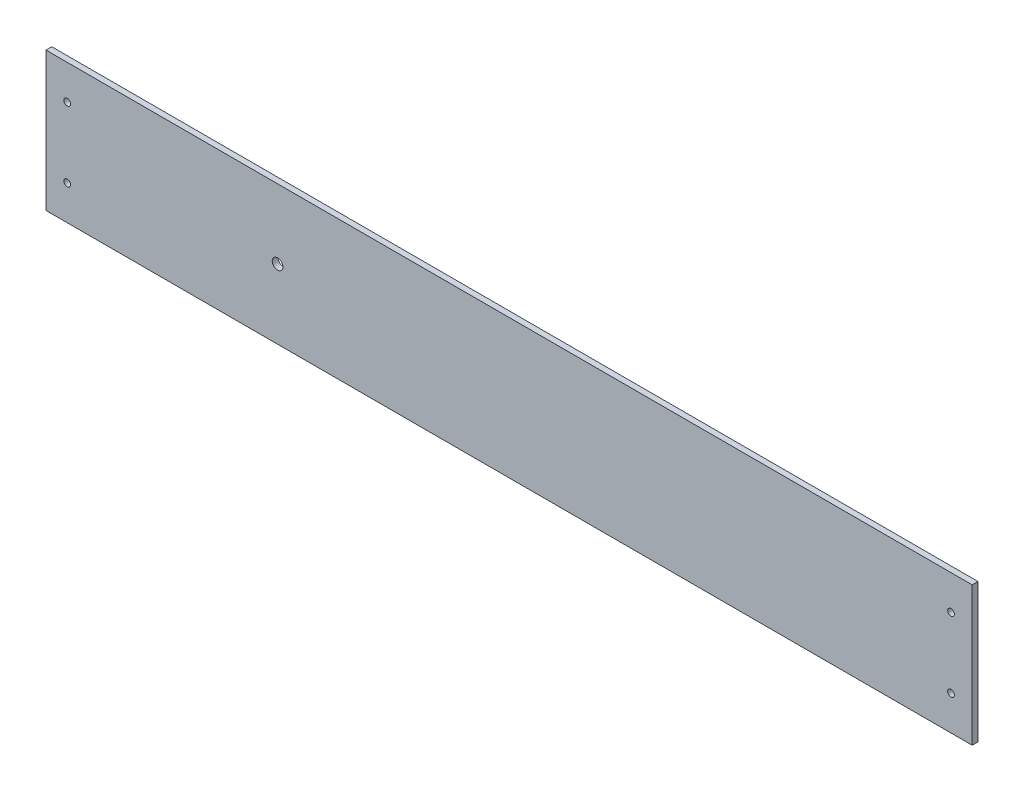
from build123d import *

# Parameters (mm, degrees)
SKETCH1_W            = 508
SKETCH1_H            = 76.2
BASIC_PLANK_DEPTH    = 3.175
SKETCH4_R            = 2.921
THROUGH_TRIPOD_DEPTH = 4.175
SKETCH5_R            = 1.8415
BRACKET_HOLES_DEPTH  = 4.175


with BuildPart() as part:
    # Sketch1 → basic_plank (new body)
    with BuildSketch(Plane.XY):
        with Locations((254, 38.1)):
            Rectangle(SKETCH1_W, SKETCH1_H)
    extrude(amount=BASIC_PLANK_DEPTH)

    # Sketch4 → through_tripod (cut, through all)
    with BuildSketch(Plane.XY.offset(3.175)):
        with Locations((127, 38.1)):
            Circle(SKETCH4_R)
    extrude(amount=-THROUGH_TRIPOD_DEPTH, mode=Mode.SUBTRACT)

    # Sketch5 → bracket holes (cut, through all)
    with BuildSketch(Plane.XY.offset(3.175)):
        with Locations((11.6078, 57.3024)):
            Circle(SKETCH5_R)
        with Locations((11.6078, 18.8976)):
            Circle(SKETCH5_R)
        with Locations((496.3922, 18.8976)):
            Circle(SKETCH5_R)
        with Locations((496.3922, 57.3024)):
            Circle(SKETCH5_R)
    extrude(amount=-BRACKET_HOLES_DEPTH, mode=Mode.SUBTRACT)


solid = part.part
